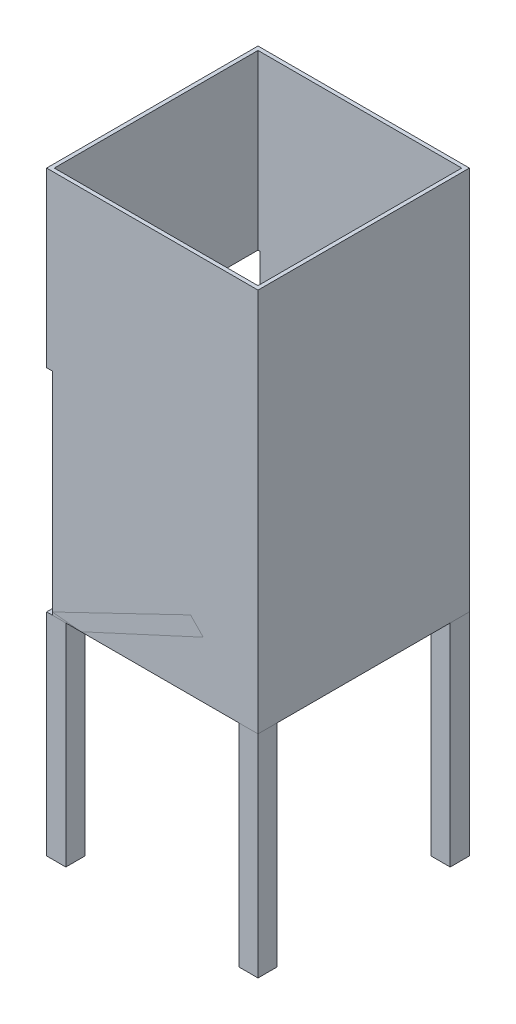
from build123d import *

# Parameters (mm, degrees)
SKETCH1_W                = 110
SKETCH1_H                = 110
BOSS_EXTRUDE1_DEPTH      = 200
SHELL1_T                 = -2
SKETCH2_W                = 10
SKETCH2_H                = 10
BOSS_EXTRUDE2_DEPTH      = 110
BOSS_EXTRUDE2_2_DEPTH    = 110
BOSS_EXTRUDE2_3_DEPTH    = 110
BOSS_EXTRUDE2_4_DEPTH    = 110
BOSS_EXTRUDE3_DEPTH      = 55
BOSS_EXTRUDE3_DEPTH_BACK = 55
SKETCH4_W                = 110
SKETCH4_H                = 110
CUT_EXTRUDE1_DEPTH       = 3


with BuildPart() as part:
    # Sketch1 → Boss-Extrude1 (new body)
    with BuildSketch(Plane(origin=(0, 0, 0), x_dir=(1, 0, 0), z_dir=(0, 1, 0))):
        Rectangle(SKETCH1_W, SKETCH1_H)
    extrude(amount=BOSS_EXTRUDE1_DEPTH)

    # Shell1
    shell1_openings = [part.faces().sort_by_distance(p)[0] for p in [
        (0, 200, 0),
    ]]
    offset(amount=SHELL1_T, openings=shell1_openings, kind=Kind.INTERSECTION)


with BuildPart() as body_2:
    # Sketch2 → Boss-Extrude2 (new body)
    with BuildSketch(Plane(origin=(0, 0, 0), x_dir=(1, 0, 0), z_dir=(0, 1, 0))):
        with Locations((50, -50)):
            Rectangle(SKETCH2_W, SKETCH2_H)
    extrude(amount=-BOSS_EXTRUDE2_DEPTH)


with BuildPart() as body_3:
    # Sketch2 → Boss-Extrude2 2 (new body)
    with BuildSketch(Plane(origin=(0, 0, 0), x_dir=(1, 0, 0), z_dir=(0, 1, 0))):
        with Locations((50, 50)):
            Rectangle(SKETCH2_W, SKETCH2_H)
    extrude(amount=-BOSS_EXTRUDE2_2_DEPTH)


with BuildPart() as body_4:
    # Sketch2 → Boss-Extrude2 3 (new body)
    with BuildSketch(Plane(origin=(0, 0, 0), x_dir=(1, 0, 0), z_dir=(0, 1, 0))):
        with Locations((-50, -50)):
            Rectangle(SKETCH2_W, SKETCH2_H)
    extrude(amount=-BOSS_EXTRUDE2_3_DEPTH)


with BuildPart() as body_5:
    # Sketch2 → Boss-Extrude2 4 (new body)
    with BuildSketch(Plane(origin=(0, 0, 0), x_dir=(1, 0, 0), z_dir=(0, 1, 0))):
        with Locations((-50, 50)):
            Rectangle(SKETCH2_W, SKETCH2_H)
    extrude(amount=-BOSS_EXTRUDE2_4_DEPTH)


with BuildPart() as body_6:
    # Sketch3 → Boss-Extrude3 (new body, two sides)
    with BuildSketch(Plane.XY) as boss_extrude3_sk:
        Polygon((-55, 0), (55, 52.981975722), (55, 42.474058316), (-37.080823924, 0), align=None)
    extrude(amount=BOSS_EXTRUDE3_DEPTH)
    extrude(boss_extrude3_sk.sketch, amount=-BOSS_EXTRUDE3_DEPTH_BACK)


with BuildPart() as cut_extrude1_tool:
    # Sketch4 → Cut-Extrude1 (new body)
    with BuildSketch(Plane.ZY.offset(55)):
        with Locations((0, 55)):
            Rectangle(SKETCH4_W, SKETCH4_H)
    extrude(amount=-CUT_EXTRUDE1_DEPTH)


with BuildPart() as part_1:
    add(part.part)

    # Cut-Extrude1: cut by cut_extrude1_tool
    add(cut_extrude1_tool.part, mode=Mode.SUBTRACT)


with BuildPart() as body_6_1:
    add(body_6.part)

    # Cut-Extrude1: cut by cut_extrude1_tool
    add(cut_extrude1_tool.part, mode=Mode.SUBTRACT)


solid = Compound([body_2.part, body_3.part, body_4.part, body_5.part, part_1.part, body_6_1.part])
